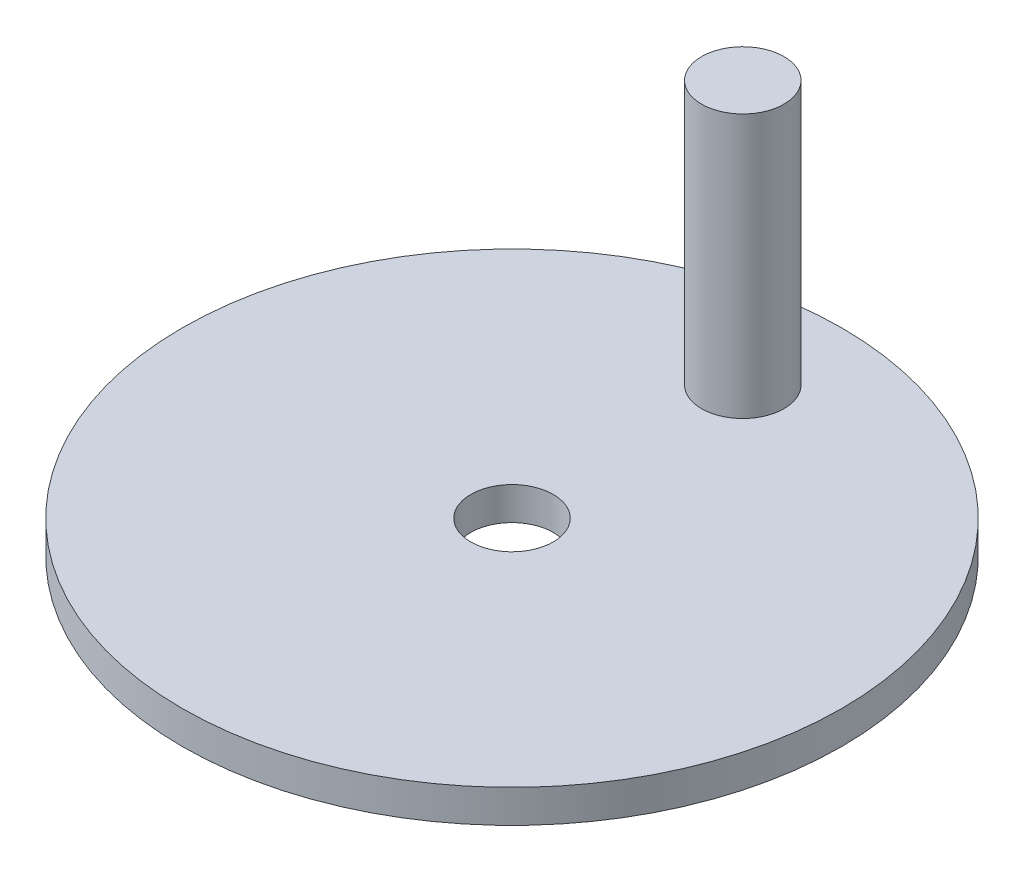
from build123d import *

# Parameters (mm, degrees)
SKETCH1_R           = 25.4
SKETCH1_R_2         = 3.175
BOSS_EXTRUDE1_DEPTH = 2.54
SKETCH2_R           = 3.175
BOSS_EXTRUDE2_DEPTH = 20.32


with BuildPart() as part:
    # Sketch1 → Boss-Extrude1 (new body)
    with BuildSketch(Plane(origin=(0, 0, 0), x_dir=(1, 0, 0), z_dir=(0, 1, 0))):
        Circle(SKETCH1_R)
        Circle(SKETCH1_R_2, mode=Mode.SUBTRACT)
    extrude(amount=BOSS_EXTRUDE1_DEPTH)

    # Sketch2 → Boss-Extrude2 (add)
    with BuildSketch(Plane(origin=(0, 2.54, 0), x_dir=(1, 0, 0), z_dir=(0, 1, 0))):
        with Locations((0, 17.78)):
            Circle(SKETCH2_R)
    extrude(amount=BOSS_EXTRUDE2_DEPTH)


solid = part.part
